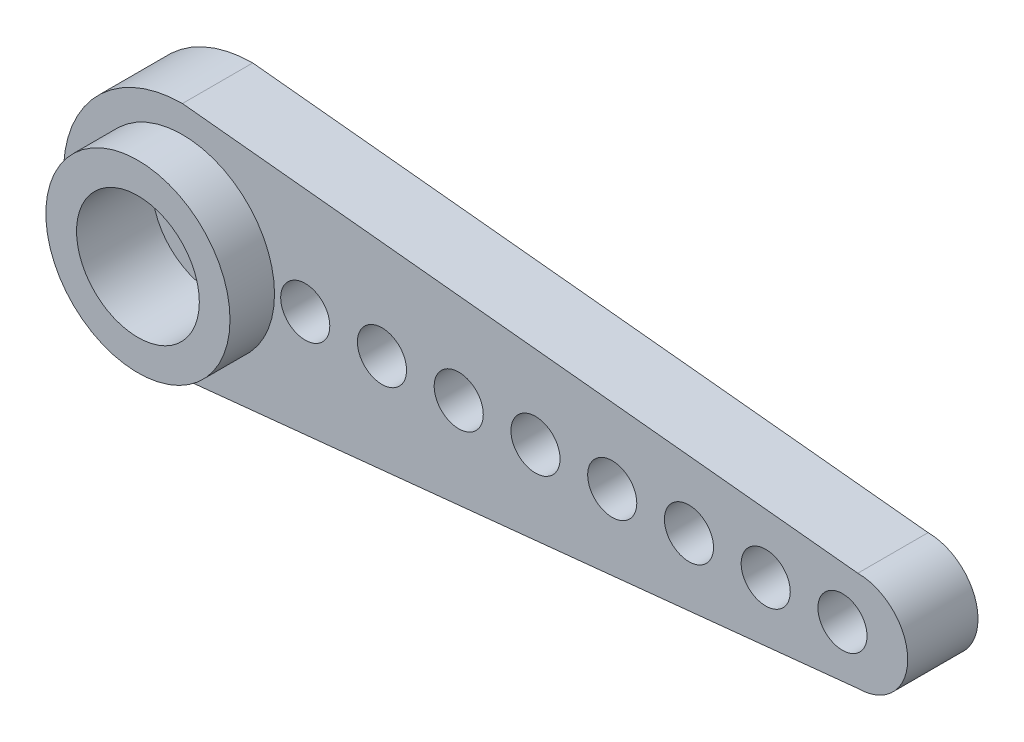
from build123d import *

# Parameters (mm, degrees)
EXTRUDE_1_DEPTH        = 4.58
SKETCH_2_R             = 6
EXTRUDE_2_DEPTH        = 2.9
SKETCH_3_R             = 4
CUT_EXTRUDE_1_DEPTH    = 4.935
SKETCH_6_R             = 4.65
EXTRUDE_3_DEPTH        = 0.4
SKETCH_7_R             = 3.8
CUT_EXTRUDE_4_DEPTH    = 0.9
SKETCH_4_R             = 1.575
CUT_EXTRUDE_2_DEPTH    = 3.945
SKETCH_5_R             = 1.6
CUT_EXTRUDE_3_DEPTH    = 8.48
PATTERN_LINEAR_1_COUNT = 8
PATTERN_LINEAR_1_PITCH = 5


with BuildPart() as part:
    # 草圖1 → 填料-伸長1 (new body)
    with BuildSketch(Plane.XY):
        with BuildLine():
            Line((1.568817891, 7.589552716), (0, 7.75))
            ThreePointArc((0, 7.75), (-7.75, 0), (0, -7.75))
            Line((0, -7.75), (1.568817891, -7.589552716))
            Line((1.568817891, -7.589552716), (44, -3.25))
            ThreePointArc((44, -3.25), (47.25, 0), (44, 3.25))
            Line((44, 3.25), (1.568817891, 7.589552716))
        make_face()
    extrude(amount=EXTRUDE_1_DEPTH)

    # 草圖2 → 填料-伸長2 (add)
    with BuildSketch(Plane.XY.offset(4.58)):
        Circle(SKETCH_2_R)
    extrude(amount=EXTRUDE_2_DEPTH)

    # 草圖3 → 除料-伸長1 (cut)
    with BuildSketch(Plane.XY.offset(7.48)):
        Circle(SKETCH_3_R)
    extrude(amount=-CUT_EXTRUDE_1_DEPTH, mode=Mode.SUBTRACT)

    # 草圖6 → 填料-伸長3 (add)
    with BuildSketch(Plane(origin=(0, 0, 0), x_dir=(-1, 0, 0), z_dir=(0, 0, -1))):
        Circle(SKETCH_6_R)
    extrude(amount=EXTRUDE_3_DEPTH)

    # 草圖7 → 除料-伸長4 (cut)
    with BuildSketch(Plane(origin=(0, 0, -0.4), x_dir=(-1, 0, 0), z_dir=(0, 0, -1))):
        Circle(SKETCH_7_R)
    extrude(amount=-CUT_EXTRUDE_4_DEPTH, mode=Mode.SUBTRACT)

    # 草圖4 → 除料-伸長2 (cut, through all)
    with BuildSketch(Plane.XY.offset(2.545)):
        Circle(SKETCH_4_R)
    extrude(amount=-CUT_EXTRUDE_2_DEPTH, mode=Mode.SUBTRACT)

    # 草圖5 → 除料-伸長3 (cut, through all)
    with BuildSketch(Plane(origin=(0, 0, 0), x_dir=(-1, 0, 0), z_dir=(0, 0, -1))):
        with Locations((-8, 0)):
            Circle(SKETCH_5_R)
    cut_extrude_3 = extrude(amount=-CUT_EXTRUDE_3_DEPTH, mode=Mode.SUBTRACT)

    # 直線複製排列1: 除料-伸長3 ×8
    with Locations(*[(i * PATTERN_LINEAR_1_PITCH, 0, 0) for i in range(1, PATTERN_LINEAR_1_COUNT)]):
        add(cut_extrude_3, mode=Mode.SUBTRACT)


solid = part.part
